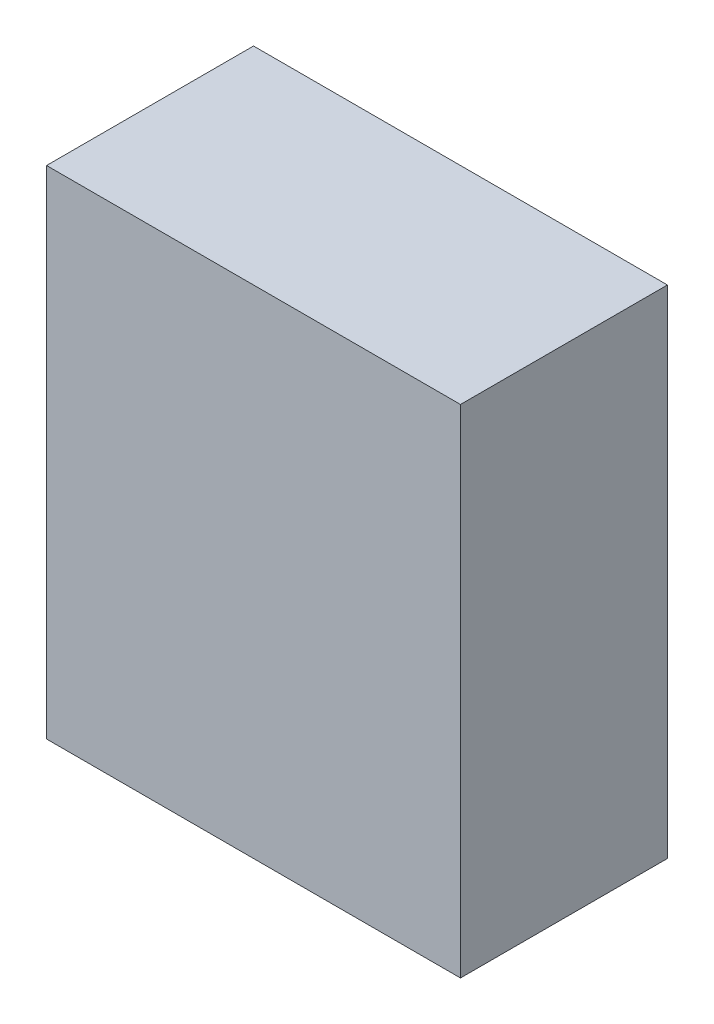
from build123d import *

# Parameters (mm, degrees)
SKETCH1_W           = 50
SKETCH1_H           = 25
BOSS_EXTRUDE1_DEPTH = 60


with BuildPart() as part:
    # Sketch1 → Boss-Extrude1 (new body)
    with BuildSketch(Plane(origin=(0, 0, 0), x_dir=(1, 0, 0), z_dir=(0, 1, 0))):
        Rectangle(SKETCH1_W, SKETCH1_H)
    extrude(amount=BOSS_EXTRUDE1_DEPTH)


solid = part.part
